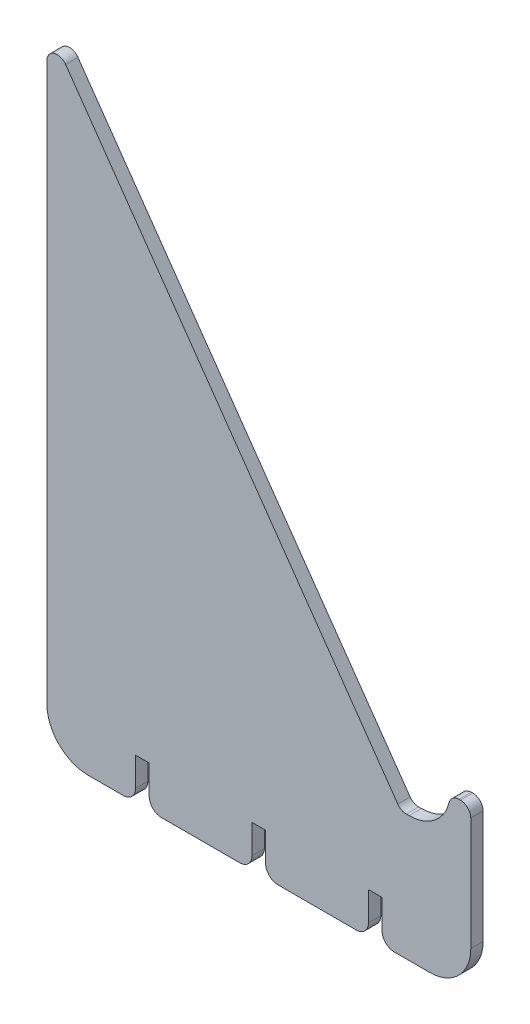
from build123d import *

# Parameters (mm, degrees)
BOSS_EXTRUDE1_DEPTH = 3
SKETCH3_W           = 3.3
SKETCH3_H           = 10
CUT_EXTRUDE1_DEPTH  = 4
FILLET1_R           = 3


with BuildPart() as part:
    # Sketch1 → Boss-Extrude1 (new body)
    with BuildSketch(Plane.XY):
        with BuildLine():
            Line((86.496300823, -131.179339344), (85.797718449, -131.179339344))
            ThreePointArc((85.797718449, -131.179339344), (84.643346916, -130.896866427), (83.749838339, -130.113280435))
            Line((83.749838339, -130.113280435), (3.007715481, -14.801578616))
            ThreePointArc((3.007715481, -14.801578616), (0.208070871, -13.85122733), (-1.54016463, -16.235519707))
            Line((-1.54016463, -16.235519707), (-1.54016463, -151.684305639))
            ThreePointArc((-1.54016463, -151.684305639), (1.388767558, -158.75537345), (8.45983537, -161.684305639))
            Line((8.45983537, -161.684305639), (91.483543137, -161.684305639))
            ThreePointArc((91.483543137, -161.684305639), (98.554610949, -158.75537345), (101.483543137, -151.684305639))
            Line((101.483543137, -151.684305639), (101.483543137, -124.184305639))
            ThreePointArc((101.483543137, -124.184305639), (100.75131009, -122.416538686), (98.983543137, -121.684305639))
            Line((98.983543137, -121.684305639), (98.629733048, -121.684305639))
            ThreePointArc((98.629733048, -121.684305639), (97.08903242, -122.215488335), (96.203046603, -123.58331238))
            ThreePointArc((96.203046603, -123.58331238), (92.659103337, -129.054608557), (86.496300823, -131.179339344))
        make_face()
    extrude(amount=BOSS_EXTRUDE1_DEPTH)

    # Sketch3 → Cut-Extrude1 (cut, through all)
    with BuildSketch(Plane(origin=(0, 0, 0), x_dir=(-1, 0, 0), z_dir=(0, 0, -1))):
        with Locations((-49.971689254, -156.684305639)):
            Rectangle(SKETCH3_W, SKETCH3_H)
        with Locations((-21.671689254, -156.684305639)):
            Rectangle(SKETCH3_W, SKETCH3_H)
        with Locations((-78.271689254, -156.684305639)):
            Rectangle(SKETCH3_W, SKETCH3_H)
    extrude(amount=-CUT_EXTRUDE1_DEPTH, mode=Mode.SUBTRACT)

    # Fillet1
    fillet1_edges = [part.edges().sort_by_distance(p)[0] for p in [
        (23.321689254, -161.684305639, 1.5),
        (20.021689254, -161.684305639, 1.5),
        (76.621689254, -161.684305639, 1.5),
        (79.921689254, -161.684305639, 1.5),
        (48.321689254, -161.684305639, 1.5),
        (51.621689254, -161.684305639, 1.5),
    ]]
    fillet(fillet1_edges, radius=FILLET1_R)


solid = part.part
